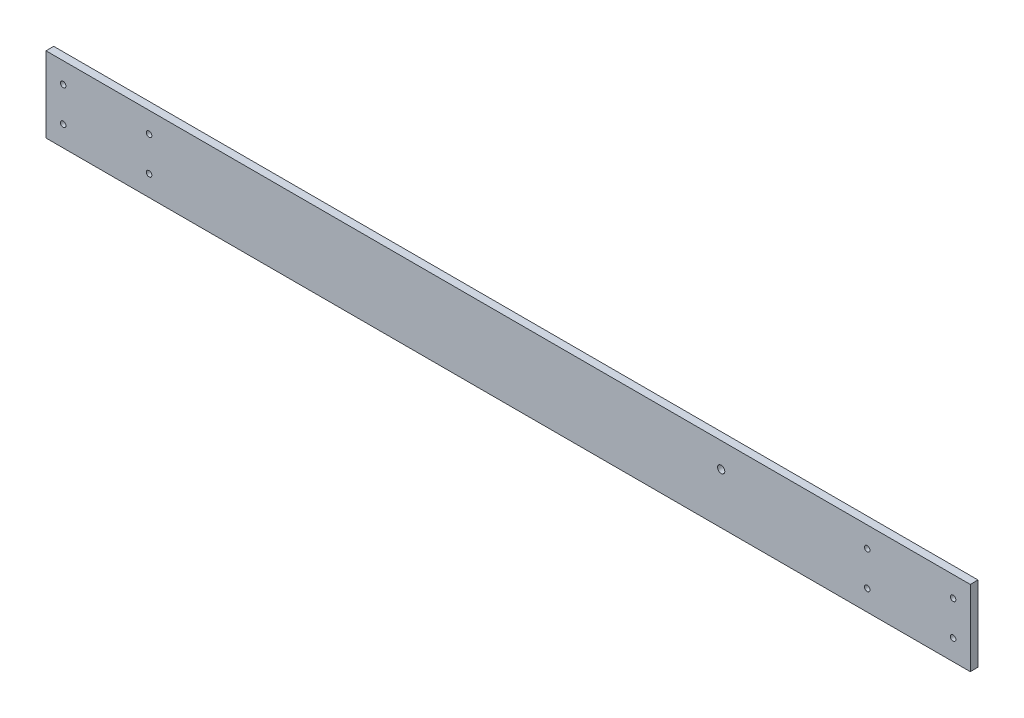
from build123d import *

# Parameters (mm, degrees)
SKETCH2_W           = 538
SKETCH2_H           = 44
SKETCH2_R           = 2.1
SKETCH2_R_2         = 1.6
BOSS_EXTRUDE1_DEPTH = 4.5


with BuildPart() as part:
    # Sketch2 → Boss-Extrude1 (new body)
    with BuildSketch(Plane.XY):
        Rectangle(SKETCH2_W, SKETCH2_H)
        with Locations((124, 7.5)):
            Circle(SKETCH2_R, mode=Mode.SUBTRACT)
        with Locations((259, 10)):
            Circle(SKETCH2_R_2, mode=Mode.SUBTRACT)
        with Locations((209, 10)):
            Circle(SKETCH2_R_2, mode=Mode.SUBTRACT)
        with Locations((209, -10)):
            Circle(SKETCH2_R_2, mode=Mode.SUBTRACT)
        with Locations((259, -10)):
            Circle(SKETCH2_R_2, mode=Mode.SUBTRACT)
        with Locations((-209, 10)):
            Circle(SKETCH2_R_2, mode=Mode.SUBTRACT)
        with Locations((-209, -10)):
            Circle(SKETCH2_R_2, mode=Mode.SUBTRACT)
        with Locations((-259, -10)):
            Circle(SKETCH2_R_2, mode=Mode.SUBTRACT)
        with Locations((-259, 10)):
            Circle(SKETCH2_R_2, mode=Mode.SUBTRACT)
    extrude(amount=BOSS_EXTRUDE1_DEPTH)


solid = part.part
